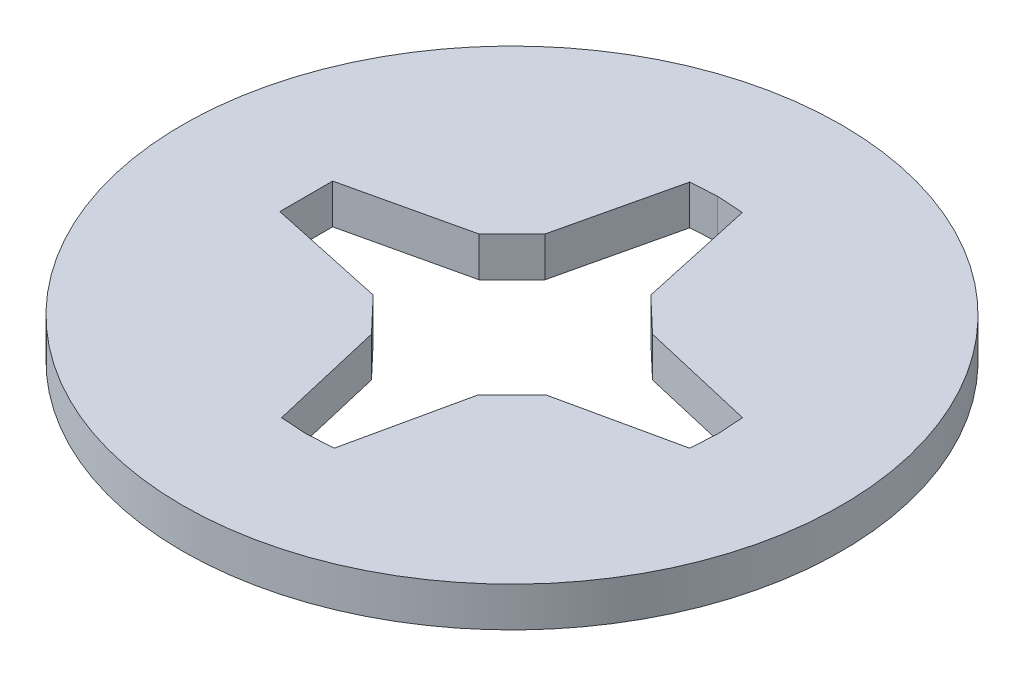
from build123d import *

# Parameters (mm, degrees)
SKETCH1_R           = 24.933599888
BOSS_EXTRUDE1_DEPTH = 3


with BuildPart() as part:
    # Sketch1 → Boss-Extrude1 (new body)
    with BuildSketch(Plane(origin=(0, 0, 0), x_dir=(1, 0, 0), z_dir=(0, 1, 0))):
        with Locations((0.066400112, -0.066400112)):
            Circle(SKETCH1_R)
        Polygon((-15.5, -0.066400112), (-15.5, 1.933599888), (-6.5, 4), (-4, 6.5), (-1.929468724, 15.371518143), (0.066400112, 15.5), (2.058453157, 15.372010982), (4, 6.5), (6.632800224, 4), (15.503783714, 1.933599888), (15.632800224, -0.066400112), (15.503783714, -2.066400112), (6.632800224, -4), (4, -6.632800224), (2.062268949, -15.504318367), (0.066400112, -15.632800224), (-1.929468724, -15.504318367), (-4, -6.632800224), (-6.5, -4), (-15.5, -2.066400112), align=None, mode=Mode.SUBTRACT)
    extrude(amount=BOSS_EXTRUDE1_DEPTH)


solid = part.part
